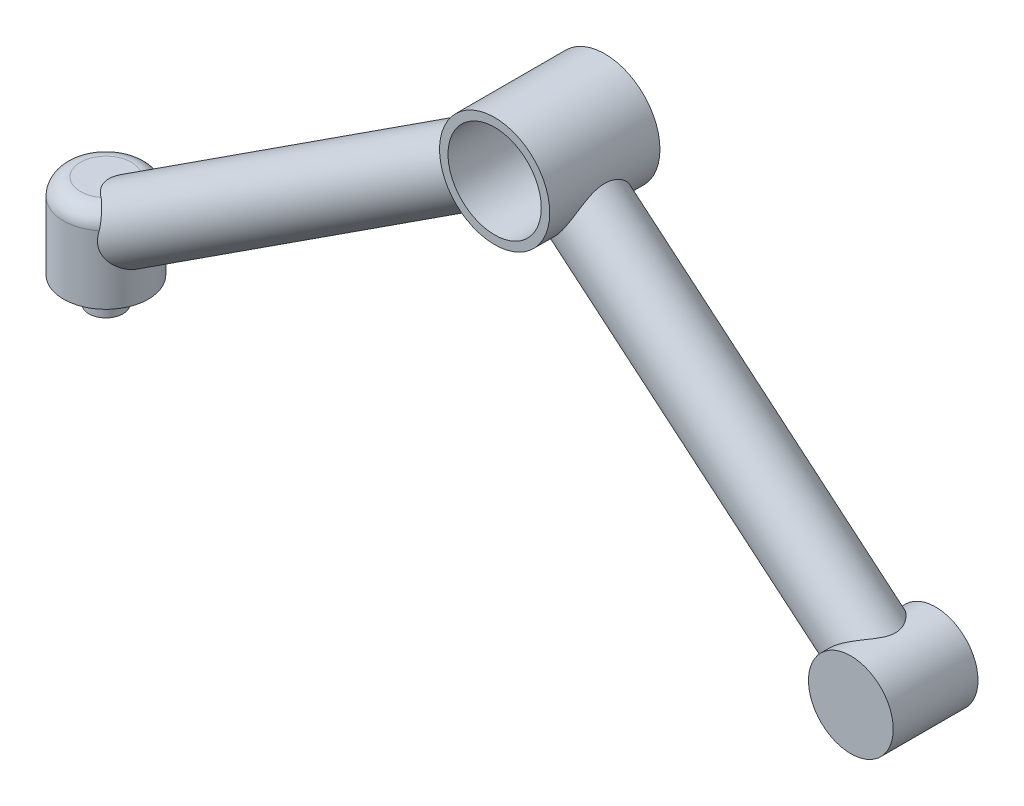
from build123d import *

# Parameters (mm, degrees)
SKETCH2_R            = 25
BOSS_EXTRUDE1_DEPTH  = 25
SKETCH4_R            = 32.5
SKETCH4_R_2          = 27.5
BOSS_EXTRUDE2_DEPTH  = 32.5
CUT_SWEEP1_PROFILE_R = 20
SWEEP1_PROFILE_R     = 20
CUT_SWEEP2_PROFILE_R = 15
BOSS_EXTRUDE3_REACH  = 402.426
SKETCH39_R           = 20
SKETCH39_R_2         = 15
BOSS_EXTRUDE4_REACH  = 337.758
SKETCH40_R           = 20
SKETCH40_R_2         = 15
SWEEP2_PROFILE_R     = 20
CUT_SWEEP3_PROFILE_R = 15
BOSS_EXTRUDE5_REACH  = 381.323
SKETCH62_R           = 20
SKETCH62_R_2         = 15
BOSS_EXTRUDE6_REACH  = 422.18
SKETCH63_R           = 20
SKETCH63_R_2         = 15
SKETCH64_R           = 10
BOSS_EXTRUDE7_DEPTH  = 15


with BuildPart() as part:
    # Sketch2 → Boss-Extrude1 (new, symmetric)
    with BuildSketch(Plane.XY):
        with Locations((202.598110741, -170)):
            Circle(SKETCH2_R)
    extrude(amount=BOSS_EXTRUDE1_DEPTH, both=True)

    # Sketch63 → Boss-Extrude6 (add, up to next)
    with BuildSketch(Plane(origin=(112.469524634, -94.373136639, 0), x_dir=(0, 0, -1), z_dir=(0.7660444431189742, -0.6427876096865439, 0)), mode=Mode.PRIVATE) as boss_extrude6_sk1:
        Circle(SKETCH63_R)
        Circle(SKETCH63_R_2, mode=Mode.SUBTRACT)
    boss_extrude6_tool1 = extrude(boss_extrude6_sk1.sketch, amount=BOSS_EXTRUDE6_REACH, mode=Mode.PRIVATE) - part.part


with BuildPart() as body_2:
    # Sketch3 → Revolve1 (revolve)
    with BuildSketch(Plane.XY):
        with BuildLine():
            Line((-236.777043848, -155), (-236.777043848, -195))
            Line((-236.777043848, -195), (-261.777043848, -195))
            Line((-261.777043848, -195), (-261.777043848, -145))
            Line((-261.777043848, -145), (-246.777043848, -145))
            ThreePointArc((-246.777043848, -145), (-239.705976037, -147.928932188), (-236.777043848, -155))
        make_face()
    revolve(axis=Axis((-261.777043848, -195, 0), (0, 1, 0)))

    # Cut-Sweep1: sweep along a path in Sketch5
    with BuildLine(Plane.XY) as cut_sweep1_path:
        Line((-261.777043848, -170), (-220.141253827, -142.961401811))
    # Cut-Sweep1 profile (on start of the path) → Cut-Sweep1 (sweep, cut)
    with BuildSketch(Plane(origin=(-261.777043848, -170, 0), x_dir=(-0.5446390350150192, 0.8386705679454292, 0), z_dir=(0.8386705679454292, 0.5446390350150192, 0))):
        Circle(CUT_SWEEP1_PROFILE_R)
    sweep(path=cut_sweep1_path.line, mode=Mode.SUBTRACT)

    # Sketch39 → Boss-Extrude3 (add, up to next)
    with BuildSketch(Plane(origin=(-149.813418547, -97.289971567, 0), x_dir=(0, 0, 1), z_dir=(-0.838670567945429, -0.5446390350150195, 0)), mode=Mode.PRIVATE) as boss_extrude3_sk1:
        Circle(SKETCH39_R)
        Circle(SKETCH39_R_2, mode=Mode.SUBTRACT)
    boss_extrude3_tool1 = extrude(boss_extrude3_sk1.sketch, amount=BOSS_EXTRUDE3_REACH, mode=Mode.PRIVATE) - body_2.part


with BuildPart() as body_3:
    # Sketch4 → Boss-Extrude2 (new, symmetric)
    with BuildSketch(Plane.XY):
        Circle(SKETCH4_R)
        Circle(SKETCH4_R_2, mode=Mode.SUBTRACT)
    extrude(amount=BOSS_EXTRUDE2_DEPTH, both=True)

    # Sketch40 → Boss-Extrude4 (add, up to next)
    with BuildSketch(Plane(origin=(-71.858653366, -46.665555133, 0), x_dir=(0, 0, -1), z_dir=(0.838670567945429, 0.5446390350150195, 0)), mode=Mode.PRIVATE) as boss_extrude4_sk1:
        Circle(SKETCH40_R)
        Circle(SKETCH40_R_2, mode=Mode.SUBTRACT)
    boss_extrude4_tool1 = extrude(boss_extrude4_sk1.sketch, amount=BOSS_EXTRUDE4_REACH, mode=Mode.PRIVATE) - body_3.part


with BuildPart() as body_4:
    # Sweep1: sweep along a path in Sketch14
    with BuildLine(Plane.XY) as sweep1_path:
        Line((-149.813418547, -97.289971567), (-71.858653366, -46.665555133))
    # Sweep1 profile (on start of the path) → Sweep1 (sweep)
    with BuildSketch(Plane(origin=(-149.813418547, -97.289971567, 0), x_dir=(-0.544639035015019, 0.8386705679454293, 0), z_dir=(0.8386705679454293, 0.544639035015019, 0))):
        Circle(SWEEP1_PROFILE_R)
    sweep(path=sweep1_path.line)

    # Cut-Sweep2: sweep along a path in Sketch14_2
    with BuildLine(Plane.XY) as cut_sweep2_path:
        Line((-149.813418547, -97.289971567), (-71.858653366, -46.665555133))
    # Cut-Sweep2 profile (on start of the path) → Cut-Sweep2 (sweep, cut)
    with BuildSketch(Plane(origin=(-149.813418547, -97.289971567, 0), x_dir=(-0.544639035015019, 0.8386705679454293, 0), z_dir=(0.8386705679454293, 0.544639035015019, 0))):
        Circle(CUT_SWEEP2_PROFILE_R)
    sweep(path=cut_sweep2_path.line, mode=Mode.SUBTRACT)


with BuildPart() as body_2_1:
    add(body_2.part)

    add(body_4.part)  # Boss-Extrude3 merges body 4
    add(boss_extrude3_tool1.solids().sort_by_distance((-149.813419, -97.289972, -19.434315))[0])


with BuildPart() as body_3_1:
    add(body_3.part)

    add(body_2_1.part)  # Boss-Extrude4 merges body 2
    add(boss_extrude4_tool1.solids().sort_by_distance((-71.858653, -46.665555, 19.434315))[0])

    # Sketch62 → Boss-Extrude5 (add, up to next)
    with BuildSketch(Plane(origin=(63.612686227, -53.377381551, 0), x_dir=(0, 0, 1), z_dir=(-0.7660444431189742, 0.6427876096865439, 0)), mode=Mode.PRIVATE) as boss_extrude5_sk1:
        Circle(SKETCH62_R)
        Circle(SKETCH62_R_2, mode=Mode.SUBTRACT)
    boss_extrude5_tool1 = extrude(boss_extrude5_sk1.sketch, amount=BOSS_EXTRUDE5_REACH, mode=Mode.PRIVATE) - body_3_1.part


with BuildPart() as body_3_2:
    # Sweep2: sweep along a path in Sketch41
    with BuildLine(Plane.XY) as sweep2_path:
        Line((63.612686227, -53.377381551), (112.469524634, -94.373136639))
    # Sweep2 profile (on start of the path) → Sweep2 (sweep)
    with BuildSketch(Plane(origin=(63.612686227, -53.377381551, 0), x_dir=(0.6427876096865435, 0.7660444431189746, 0), z_dir=(0.7660444431189746, -0.6427876096865435, 0))):
        Circle(SWEEP2_PROFILE_R)
    sweep(path=sweep2_path.line)

    # Cut-Sweep3: sweep along a path in Sketch41_2
    with BuildLine(Plane.XY) as cut_sweep3_path:
        Line((63.612686227, -53.377381551), (112.469524634, -94.373136639))
    # Cut-Sweep3 profile (on start of the path) → Cut-Sweep3 (sweep, cut)
    with BuildSketch(Plane(origin=(63.612686227, -53.377381551, 0), x_dir=(0.6427876096865435, 0.7660444431189746, 0), z_dir=(0.7660444431189746, -0.6427876096865435, 0))):
        Circle(CUT_SWEEP3_PROFILE_R)
    sweep(path=cut_sweep3_path.line, mode=Mode.SUBTRACT)


with BuildPart() as body_3_3:
    add(body_3_1.part)

    add(body_3_2.part)  # Boss-Extrude5 merges body 3 2
    add(boss_extrude5_tool1.solids().sort_by_distance((63.612686, -53.377382, -19.434315))[0])


with BuildPart() as part_1:
    add(part.part)

    add(body_3_3.part)  # Boss-Extrude6 merges body 3
    add(boss_extrude6_tool1.solids().sort_by_distance((112.469525, -94.373137, 19.434315))[0])

    # Sketch64 → Boss-Extrude7 (add)
    with BuildSketch(Plane.XZ.offset(195)):
        with Locations((-261.777043848, 0)):
            Circle(SKETCH64_R)
    extrude(amount=BOSS_EXTRUDE7_DEPTH)


solid = part_1.part
